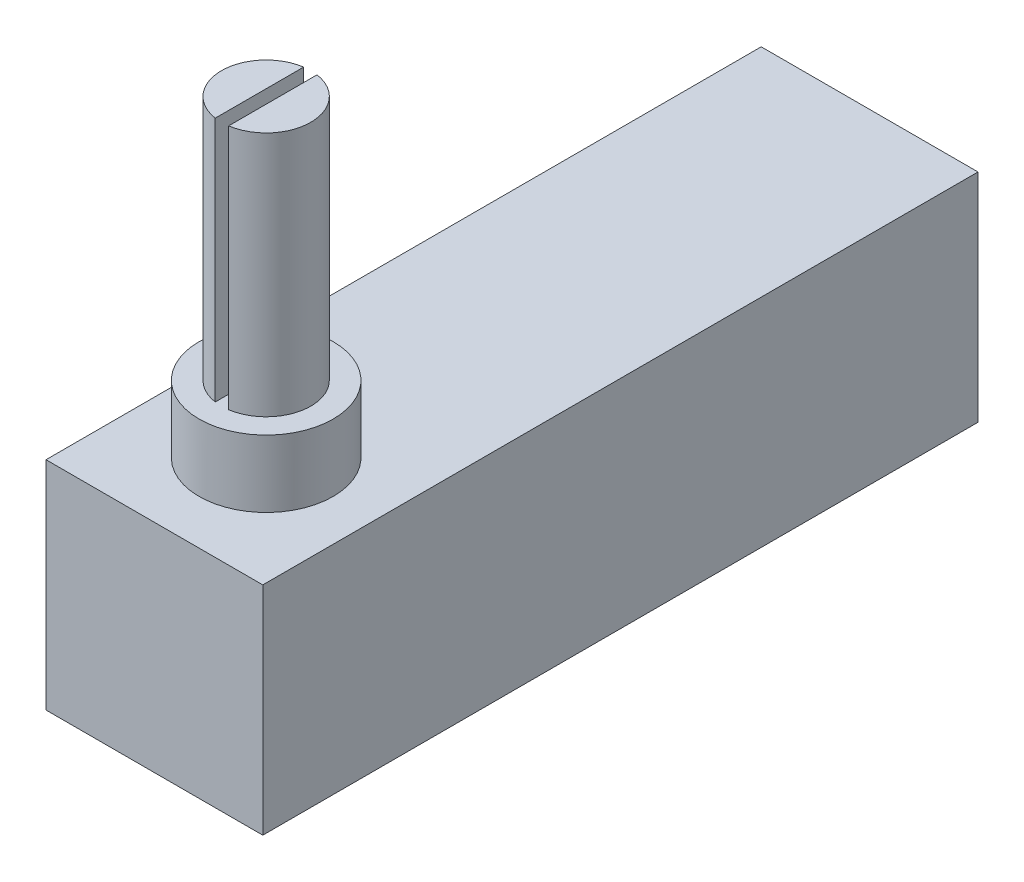
from build123d import *

# Parameters (mm, degrees)
SKETCH1_W           = 12.319
SKETCH1_H           = 12.319
BOSS_EXTRUDE1_DEPTH = 40.64
BOSS_EXTRUDE2_DEPTH = 17.78
SKETCH3_R           = 3.81
BOSS_EXTRUDE3_DEPTH = 3.81


with BuildPart() as part:
    # Sketch1 → Boss-Extrude1 (new body)
    with BuildSketch(Plane.XY):
        with Locations((0, -6.1595)):
            Rectangle(SKETCH1_W, SKETCH1_H)
    extrude(amount=BOSS_EXTRUDE1_DEPTH)

    # Sketch2 → Boss-Extrude2 (add)
    with BuildSketch(Plane(origin=(0, 0, 0), x_dir=(1, 0, 0), z_dir=(0, 1, 0))):
        with BuildLine():
            Line((-0.381, -31.778737568), (-0.381, -36.801262432))
            ThreePointArc((-0.381, -36.801262432), (-2.54, -34.29), (-0.381, -31.778737568))
        make_face()
        with BuildLine():
            Line((0.381, -31.778737568), (0.381, -36.801262432))
            ThreePointArc((0.381, -36.801262432), (2.54, -34.29), (0.381, -31.778737568))
        make_face()
    extrude(amount=BOSS_EXTRUDE2_DEPTH)

    # Sketch3 → Boss-Extrude3 (add)
    with BuildSketch(Plane(origin=(0, 0, 0), x_dir=(1, 0, 0), z_dir=(0, 1, 0))):
        with Locations((0, -34.29)):
            Circle(SKETCH3_R)
    extrude(amount=BOSS_EXTRUDE3_DEPTH)


solid = part.part
